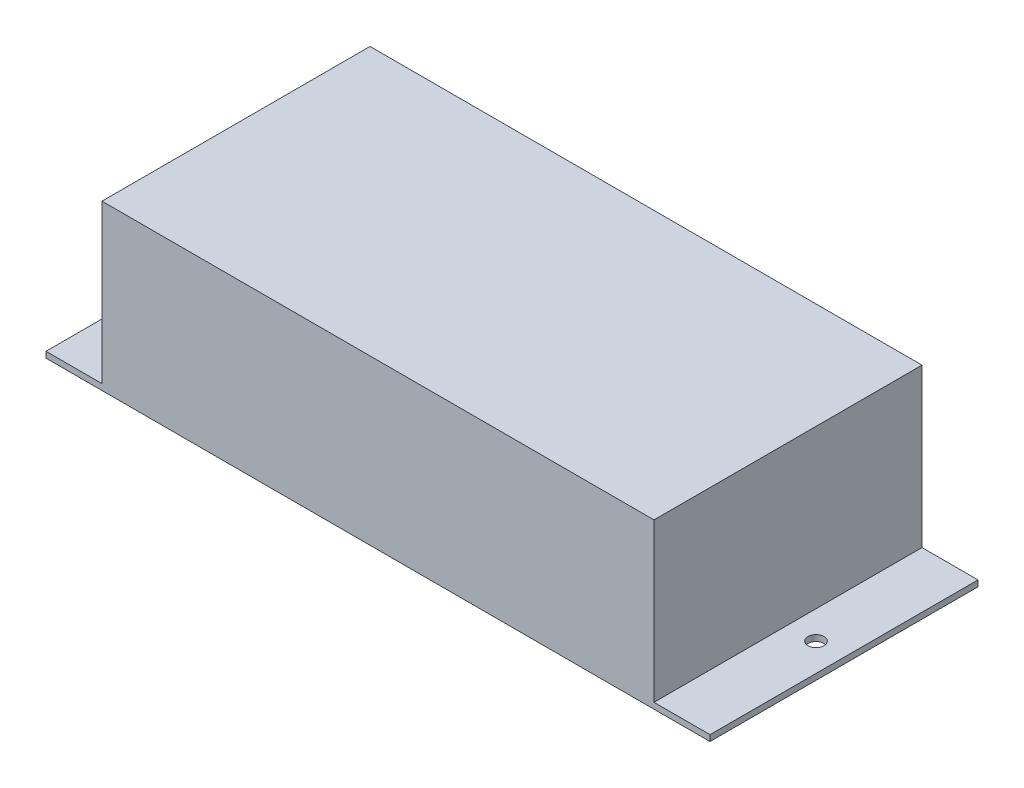
from build123d import *

# Parameters (mm, degrees)
BOSS_EXTRUDE1_DEPTH       = 67
F_4_0MM_DOWEL_HOLE1_D     = 4
F_4_0MM_DOWEL_HOLE1_DEPTH = 1.5


with BuildPart() as part:
    # Sketch2 → Boss-Extrude1 (new body)
    with BuildSketch(Plane.XY):
        Polygon((83, 0), (-83, 0), (-83, 1.5), (-69, 1.5), (-69, 41), (69, 41), (69, 1.5), (83, 1.5), align=None)
    extrude(amount=BOSS_EXTRUDE1_DEPTH)

    # Ø4.0mm Dowel Hole1
    with Locations(Plane(origin=(0, 1.5, 0), x_dir=(1, 0, 0), z_dir=(0, 1, 0))):
        with Locations((-76, -33.5), (76, -33.5)):
            Hole(F_4_0MM_DOWEL_HOLE1_D / 2, depth=F_4_0MM_DOWEL_HOLE1_DEPTH)


solid = part.part
